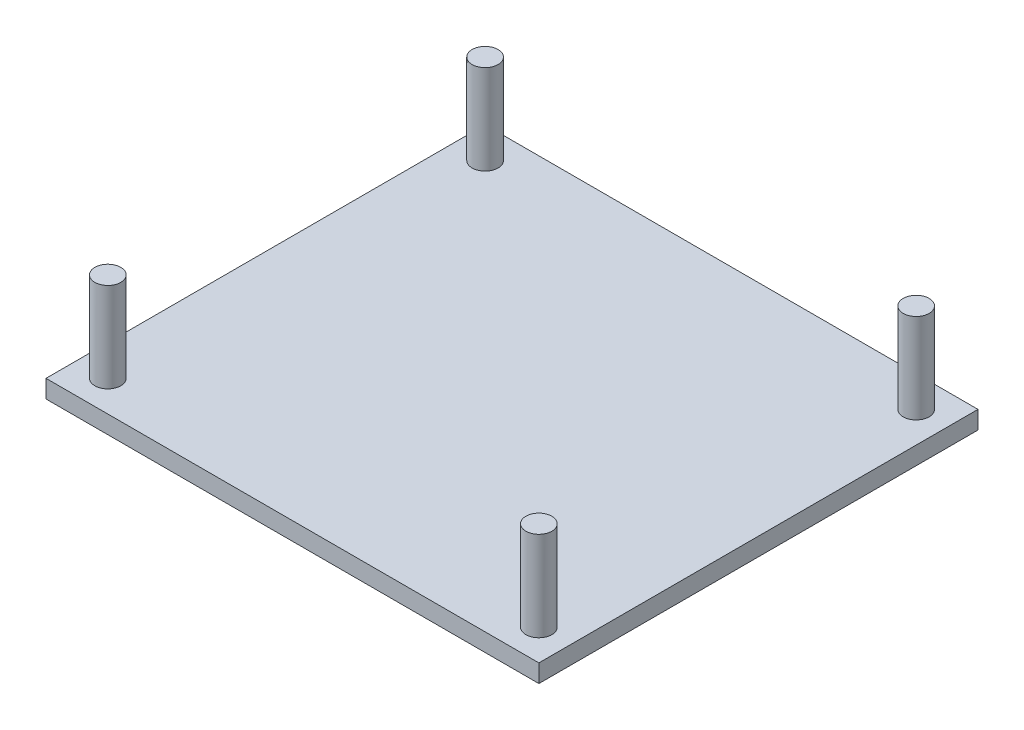
from build123d import *

# Parameters (mm, degrees)
SKETCH1_W           = 55
SKETCH1_H           = 49
BOSS_EXTRUDE1_DEPTH = 2
SKETCH2_R           = 1.45
BOSS_EXTRUDE2_DEPTH = 10


with BuildPart() as part:
    # Sketch1 → Boss-Extrude1 (new body)
    with BuildSketch(Plane(origin=(0, 0, 0), x_dir=(1, 0, 0), z_dir=(0, 1, 0))):
        with Locations((27.5, 24.5)):
            Rectangle(SKETCH1_W, SKETCH1_H)
    extrude(amount=-BOSS_EXTRUDE1_DEPTH)

    # Sketch2 → Boss-Extrude2 (add)
    with BuildSketch(Plane(origin=(0, 0, 0), x_dir=(1, 0, 0), z_dir=(0, 1, 0))):
        with Locations((3.45, 3.45)):
            Circle(SKETCH2_R)
        with Locations((51.550000042, 3.45)):
            Circle(SKETCH2_R)
        with Locations((51.550000042, 45.55)):
            Circle(SKETCH2_R)
        with Locations((3.45, 45.55)):
            Circle(SKETCH2_R)
    extrude(amount=BOSS_EXTRUDE2_DEPTH)


solid = part.part
